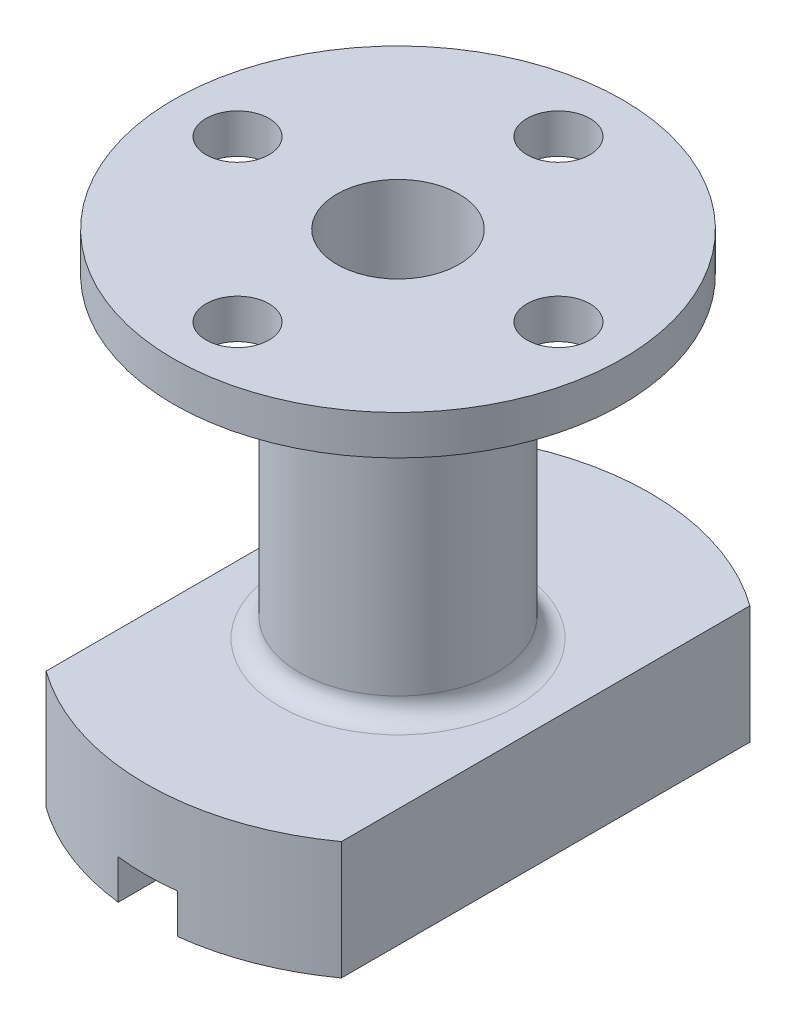
from build123d import *

# Parameters (mm, degrees)
EXTRUDE_1_DEPTH     = 6
CUT_EXTRUDE_1_DEPTH = 2
SKETCH_4_R          = 5
EXTRUDE_2_DEPTH     = 16
CUT_EXTRUDE_3_REACH = 24
SKETCH_7_R          = 3.1
FILLET_1_R          = 1
SKETCH_8_R          = 11.4
EXTRUDE_3_DEPTH     = 2
SKETCH_9_R          = 3.1
CUT_EXTRUDE_4_DEPTH = 2
SKETCH_10_R         = 1.6
CUT_EXTRUDE_5_DEPTH = 2


with BuildPart() as part:
    # 草图1 → 凸台-拉伸1 (new body)
    with BuildSketch(Plane(origin=(0, 0, 0), x_dir=(1, 0, 0), z_dir=(0, 1, 0))):
        with BuildLine():
            Line((-7.5, 10.372559954), (-7.5, -10.372559954))
            ThreePointArc((-7.5, -10.372559954), (0, -12.8), (7.5, -10.372559954))
            Line((7.5, -10.372559954), (7.5, 10.372559954))
            ThreePointArc((7.5, 10.372559954), (0, 12.8), (-7.5, 10.372559954))
        make_face()
    extrude(amount=EXTRUDE_1_DEPTH)

    # 草图2 → 切除-拉伸1 (cut)
    with BuildSketch(Plane.XZ):
        with BuildLine():
            Line((-1.5, 12.711805537), (-1.5, -12.711805537))
            ThreePointArc((-1.5, -12.711805537), (0, -12.8), (1.5, -12.711805537))
            Line((1.5, -12.711805537), (1.5, 12.711805537))
            ThreePointArc((1.5, 12.711805537), (0, 12.8), (-1.5, 12.711805537))
        make_face()
    extrude(amount=-CUT_EXTRUDE_1_DEPTH, mode=Mode.SUBTRACT)

    # 草图4 → 凸台-拉伸2 (add)
    with BuildSketch(Plane(origin=(0, 6, 0), x_dir=(1, 0, 0), z_dir=(0, 1, 0))):
        Circle(SKETCH_4_R)
    extrude(amount=EXTRUDE_2_DEPTH)

    # 草图7 → 切除-拉伸3 (cut, up to next)
    with BuildSketch(Plane.XZ, mode=Mode.PRIVATE) as cut_extrude_3_sk1:
        Circle(SKETCH_7_R)
    cut_extrude_3_tool1 = extrude(cut_extrude_3_sk1.sketch, amount=-CUT_EXTRUDE_3_REACH, mode=Mode.PRIVATE) & part.part
    add(cut_extrude_3_tool1.solids().sort_by_distance((0, 0, 0))[0], mode=Mode.SUBTRACT)

    # 圆角1
    fillet_1_edges = [part.edges().sort_by_distance(p)[0] for p in [
        (-5, 6, 0),
    ]]
    fillet(fillet_1_edges, radius=FILLET_1_R)

    # 草图8 → 凸台-拉伸3 (add)
    with BuildSketch(Plane(origin=(0, 22, 0), x_dir=(1, 0, 0), z_dir=(0, 1, 0))):
        Circle(SKETCH_8_R)
    extrude(amount=EXTRUDE_3_DEPTH)

    # 草图9 → 切除-拉伸4 (cut)
    with BuildSketch(Plane.XZ.offset(-22)):
        Circle(SKETCH_9_R)
    extrude(amount=-CUT_EXTRUDE_4_DEPTH, mode=Mode.SUBTRACT)

    # 草图10 → 切除-拉伸5 (cut)
    with BuildSketch(Plane(origin=(0, 24, 0), x_dir=(1, 0, 0), z_dir=(0, 1, 0))):
        with Locations((0, 8.15)):
            Circle(SKETCH_10_R)
        with Locations((0, -8.15)):
            Circle(SKETCH_10_R)
        with Locations((-8.15, 0)):
            Circle(SKETCH_10_R)
        with Locations((8.15, 0)):
            Circle(SKETCH_10_R)
    extrude(amount=-CUT_EXTRUDE_5_DEPTH, mode=Mode.SUBTRACT)


solid = part.part
